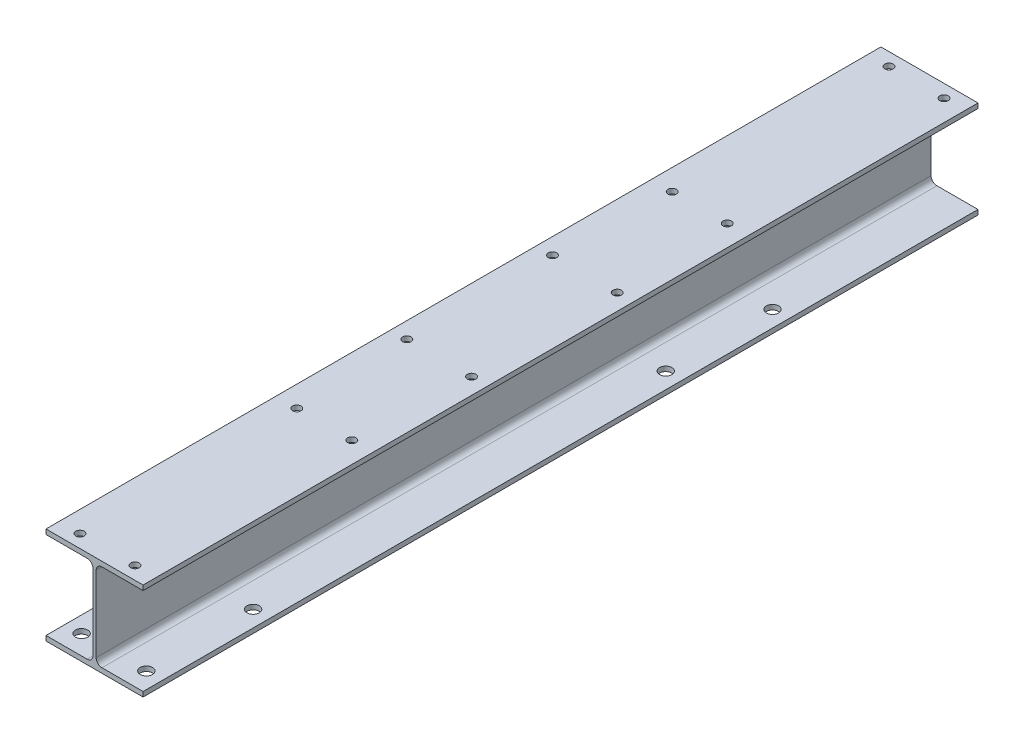
from build123d import *

# Parameters (mm, degrees)
EXTRUDE_1_DEPTH     = 1290
SKETCH_2_R          = 19
CUT_EXTRUDE_1_DEPTH = 60
SKETCH_3_R          = 13
CUT_EXTRUDE_2_DEPTH = 60


with BuildPart() as part:
    # Эскиз1 → Бобышка-Вытянуть1 (new body, symmetric)
    with BuildSketch(Plane.XY):
        with BuildLine():
            Line((150, 300), (-150, 300))
            Line((-150, 300), (-150, 285))
            Line((-150, 285), (-23, 285))
            ThreePointArc((-23, 285), (-10.272077939, 279.727922061), (-5, 267))
            Line((-5, 267), (-5, 33))
            ThreePointArc((-5, 33), (-10.272077939, 20.272077939), (-23, 15))
            Line((-23, 15), (-150, 15))
            Line((-150, 15), (-150, 0))
            Line((-150, 0), (150, 0))
            Line((150, 0), (150, 15))
            Line((150, 15), (23, 15))
            ThreePointArc((23, 15), (10.272077939, 20.272077939), (5, 33))
            Line((5, 33), (5, 267))
            ThreePointArc((5, 267), (10.272077939, 279.727922061), (23, 285))
            Line((23, 285), (150, 285))
            Line((150, 285), (150, 300))
        make_face()
    extrude(amount=EXTRUDE_1_DEPTH, both=True)

    # Эскиз2 → Вырез-Вытянуть1 (cut)
    with BuildSketch(Plane.XZ):
        with Locations((-100, 1230)):
            Circle(SKETCH_2_R)
        with Locations((100, 1230)):
            Circle(SKETCH_2_R)
        with Locations((-100, 900)):
            Circle(SKETCH_2_R)
        with Locations((100, 900)):
            Circle(SKETCH_2_R)
        with Locations((-100, -705)):
            Circle(SKETCH_2_R)
        with Locations((100, -705)):
            Circle(SKETCH_2_R)
        with Locations((-100, -375)):
            Circle(SKETCH_2_R)
        with Locations((100, -375)):
            Circle(SKETCH_2_R)
    extrude(amount=-CUT_EXTRUDE_1_DEPTH, mode=Mode.SUBTRACT)

    # Эскиз3 → Вырез-Вытянуть2 (cut)
    with BuildSketch(Plane(origin=(0, 300, 0), x_dir=(1, 0, 0), z_dir=(0, 1, 0))):
        with Locations((-85, -1250)):
            Circle(SKETCH_3_R)
        with Locations((85, -1250)):
            Circle(SKETCH_3_R)
        with Locations((-85, -580)):
            Circle(SKETCH_3_R)
        with Locations((85, -580)):
            Circle(SKETCH_3_R)
        with Locations((-100, -225)):
            Circle(SKETCH_3_R)
        with Locations((100, -225)):
            Circle(SKETCH_3_R)
        with Locations((-100, 225)):
            Circle(SKETCH_3_R)
        with Locations((100, 225)):
            Circle(SKETCH_3_R)
        with Locations((-85, 580)):
            Circle(SKETCH_3_R)
        with Locations((85, 580)):
            Circle(SKETCH_3_R)
        with Locations((-85, 1250)):
            Circle(SKETCH_3_R)
        with Locations((85, 1250)):
            Circle(SKETCH_3_R)
    extrude(amount=-CUT_EXTRUDE_2_DEPTH, mode=Mode.SUBTRACT)


solid = part.part
